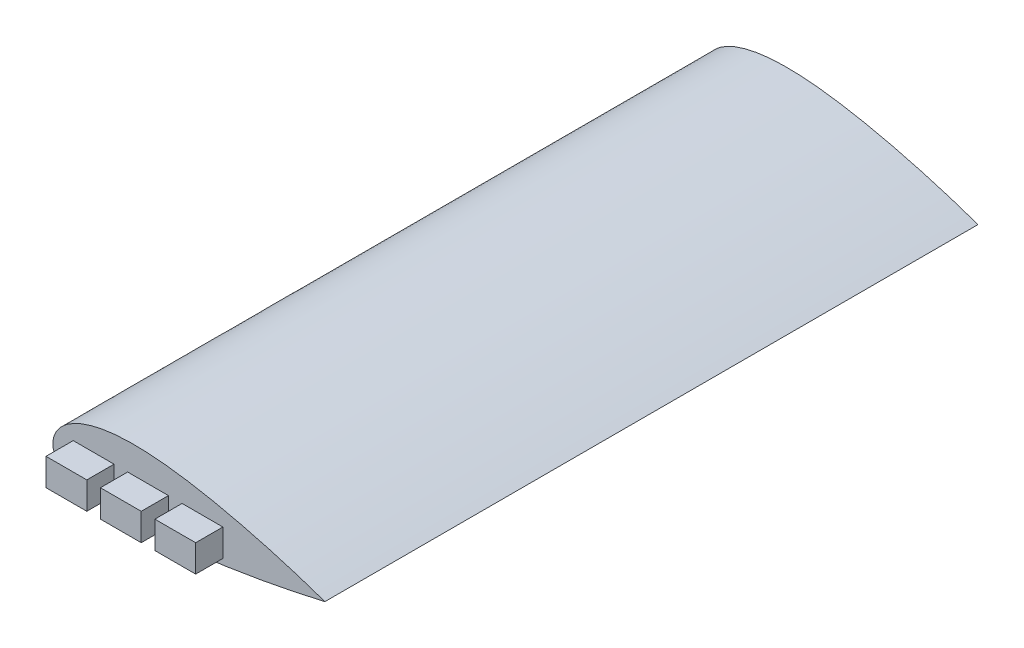
from build123d import *

# Parameters (mm, degrees)
BOSS_EXTRUDE1_DEPTH     = 125
CUT_EXTRUDE1_DEPTH      = 110
CUT_EXTRUDE1_DEPTH_BACK = 120
SKETCH8_OUTSIDE_W       = 156.08
SKETCH8_OUTSIDE_H       = 80.93
SKETCH8_OUTSIDE_W_2     = 15
SKETCH8_OUTSIDE_H_2     = 10
CUT_EXTRUDE2_DEPTH      = 10


with BuildPart() as part:
    # Sketch1 → Boss-Extrude1 (new body, symmetric)
    with BuildSketch(Plane.XY):
        with BuildLine():
            add(Edge.make_bspline(
                [(0, 0), (0.000850995, 0.329659199), (0.029549865, 0.927472015), (0.14385133, 1.796745902), (0.437026819, 2.918116545), (0.854897816, 3.99067399), (1.431457873, 5.075606208), (2.192315162, 6.177305776), (3.200330795, 7.329994922), (4.495933807, 8.510625759), (6.154032841, 9.714948919), (8.274086435, 10.929186229), (10.956963281, 12.114631433), (14.147653492, 13.152534318), (18.040460609, 14.036328853), (23.13432232, 14.736569605), (29.235682959, 15.027445823), (35.337980191, 14.824799668), (41.101061226, 14.313753112), (46.84100573, 13.596774566), (51.603718071, 12.850513756), (56.345578755, 11.983351698), (61.067148387, 11.013921336), (64.832774323, 10.182970339), (68.586460194, 9.301464098), (72.329426272, 8.372556112), (76.059801155, 7.399362237), (79.315748534, 6.509324276), (82.095955547, 5.720960272), (84.412746103, 5.044415193), (86.253737616, 4.495737821), (88.110746108, 3.929395104), (89.928948501, 3.364622885), (91.806033909, 2.766575591), (93.571042413, 2.195551738), (95.520153622, 1.546294126), (97.13830136, 1.000944859), (98.775140125, 0.431667147), (99.586664269, 0.14652965), (100.000220498, 0)],
                knots=[0, 0, 0, 0, 0, 0.011046069, 0.020081733, 0.029325805, 0.03880189, 0.049580055, 0.06120956, 0.074146174, 0.090070544, 0.108265326, 0.129826997, 0.155964864, 0.18830697, 0.220649281, 0.263591413, 0.32827592, 0.392960436, 0.425302696, 0.457644956, 0.52232947, 0.55467173, 0.58701399, 0.619356253, 0.651698515, 0.684040775, 0.716383035, 0.748725291, 0.764896419, 0.781067547, 0.797238677, 0.813409806, 0.829580935, 0.845752065, 0.861923198, 0.878094331, 0.894265464, 0.910433902, 0.910433902, 0.910433902, 0.910433902, 0.910433902], degree=4))
            add(Edge.make_bspline(
                [(0, 0), (0.000283694, -0.169267254), (0.015976794, -0.461371136), (0.077487025, -0.88514164), (0.233270026, -1.435649885), (0.451244669, -1.960918505), (0.763020391, -2.515682909), (1.196819683, -3.111846412), (1.800946429, -3.766711239), (2.645862845, -4.495413172), (3.845009807, -5.315163118), (5.520192869, -6.210587445), (7.890487327, -7.180714875), (10.947062049, -8.096276481), (15.429604607, -9.039640979), (21.207967366, -9.730011133), (27.977535992, -10.02746215), (35.648602876, -9.889128299), (42.346864335, -9.465706657), (48.074827103, -8.93985543), (53.791477179, -8.306095929), (59.496830619, -7.576550222), (65.188499989, -6.746051578), (70.86666832, -5.830240622), (75.589869863, -5.014181774), (79.362447213, -4.33071773), (82.659602016, -3.705830248), (85.480106996, -3.151491524), (87.596226543, -2.723280533), (89.000489113, -2.434123885), (90.181059485, -2.187185496), (91.104029231, -1.992562417), (92.305099816, -1.735390328), (93.655404022, -1.443860687), (95.389810689, -1.059643077), (97.102663756, -0.674849293), (98.714450572, -0.301843412), (99.575627153, -0.100232022), (100.000220498, 0)],
                knots=[0, 0, 0, 0, 0, 0.005887152, 0.010193359, 0.014866851, 0.019889426, 0.025655397, 0.032314697, 0.040497527, 0.050864902, 0.064448179, 0.082823086, 0.106555664, 0.139953895, 0.175459216, 0.242255956, 0.309052716, 0.375849477, 0.442646237, 0.47604462, 0.509443003, 0.576239764, 0.643036527, 0.676434909, 0.709833291, 0.743231671, 0.77663005, 0.793329242, 0.810028433, 0.818378029, 0.826727624, 0.83507722, 0.843426816, 0.860126007, 0.876825198, 0.893524389, 0.91022358, 0.91022358, 0.91022358, 0.91022358, 0.91022358], degree=4))
        make_face()
    extrude(amount=BOSS_EXTRUDE1_DEPTH, both=True)

    # Sketch6 → Cut-Extrude1 (cut, two sides)
    with BuildSketch(Plane.XY) as cut_extrude1_sk:
        with BuildLine():
            add(Edge.make_bspline(
                [(5.003866411, 0.16593331), (5.021771107, 0.603167174), (5.179582681, 1.45668418), (5.828059264, 2.731623867), (6.970434665, 4.055197794), (9.059941641, 5.70999826), (12.439790451, 7.406031049), (17.102385774, 8.772586441), (22.086939339, 9.580996278), (28.969887571, 10.04915127), (37.811358565, 9.719164197), (48.519550578, 8.365627259), (62.800967104, 5.688073766), (73.468720144, 2.987314718), (80.492223408, 0.975075783)],
                knots=[0.003107056, 0.003107056, 0.003107056, 0.003107056, 0.026472192, 0.049837329, 0.073202466, 0.096567602, 0.143297876, 0.190028149, 0.236758422, 0.283488695, 0.376949242, 0.470409788, 0.563870335, 0.750791428, 0.750791428, 0.750791428, 0.750791428], degree=3))
            add(Edge.make_bspline(
                [(80.492223408, 0.975075783), (73.808709309, -0.294311553), (63.724097701, -1.995472923), (50.2739718, -3.721966825), (40.201550005, -4.64981718), (31.854573956, -4.99623266), (25.257558055, -4.894657534), (20.376304938, -4.583057975), (16.407020376, -4.077297068), (13.341823588, -3.482519629), (11.126614852, -2.928004065), (9.036775347, -2.250698534), (7.465669402, -1.576012545), (6.39422808, -0.985208256), (5.718999313, -0.532122097), (5.309123649, -0.182799424), (5.089567118, 0.053028449), (5.034725373, 0.122545069), (5.003866411, 0.16593331)],
                knots=[0.025550827, 0.025550827, 0.025550827, 0.025550827, 0.20536823, 0.295276931, 0.385185632, 0.475094334, 0.520048685, 0.565003035, 0.609957386, 0.632434561, 0.654911737, 0.677388912, 0.699866088, 0.711104675, 0.722343263, 0.733581851, 0.739201144, 0.744820438, 0.744820438, 0.744820438, 0.744820438], degree=3))
        make_face()
    extrude(amount=CUT_EXTRUDE1_DEPTH, mode=Mode.SUBTRACT)
    extrude(cut_extrude1_sk.sketch, amount=-CUT_EXTRUDE1_DEPTH_BACK, mode=Mode.SUBTRACT)

    # Sketch8 outside → Cut-Extrude2 (cut)
    with BuildSketch(Plane.XY.offset(125)):
        with Locations((50, 2.485)):
            Rectangle(SKETCH8_OUTSIDE_W, SKETCH8_OUTSIDE_H)
        with Locations((35, 0)):
            Rectangle(SKETCH8_OUTSIDE_W_2, SKETCH8_OUTSIDE_H_2, mode=Mode.SUBTRACT)
        with Locations((15, 0)):
            Rectangle(SKETCH8_OUTSIDE_W_2, SKETCH8_OUTSIDE_H_2, mode=Mode.SUBTRACT)
        with Locations((55, 0)):
            Rectangle(SKETCH8_OUTSIDE_W_2, SKETCH8_OUTSIDE_H_2, mode=Mode.SUBTRACT)
    extrude(amount=-CUT_EXTRUDE2_DEPTH, mode=Mode.SUBTRACT)


solid = part.part
